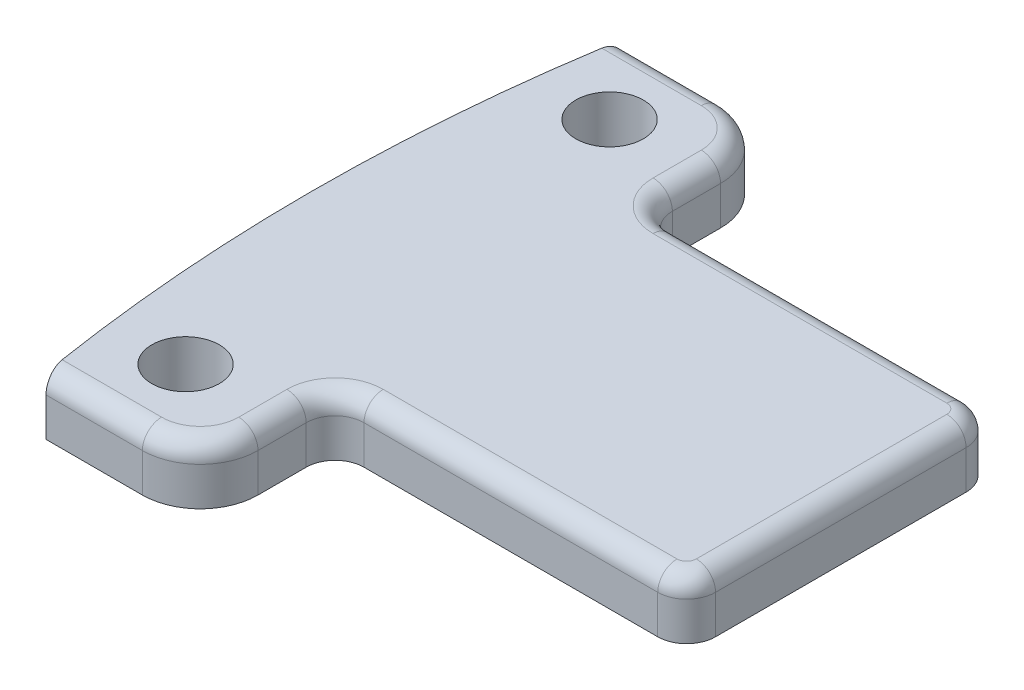
from build123d import *

# Parameters (mm, degrees)
BOSS_EXTRUDE1_DEPTH = 3
SKETCH2_R           = 1.75
CUT_EXTRUDE1_DEPTH  = 4
FILLET1_R           = 1.5
FILLET3_R           = 3
FILLET2_R           = 1


with BuildPart() as part:
    # Sketch1 → Boss-Extrude1 (new body)
    with BuildSketch(Plane(origin=(0, 0, 0), x_dir=(1, 0, 0), z_dir=(0, 1, 0))):
        with BuildLine():
            Line((-12.491196746, 15), (-4.491196746, 15))
            Line((-4.491196746, 15), (-4.491196746, 8))
            Line((-4.491196746, 8), (13.75, 8))
            Line((13.75, 8), (13.75, -8))
            Line((13.75, -8), (-4.491196746, -8))
            Line((-4.491196746, -8), (-4.491196746, -15))
            Line((-4.491196746, -15), (-12.491196746, -15))
            ThreePointArc((-12.491196746, -15), (-13.75, 0), (-12.491196746, 15))
        make_face()
    extrude(amount=BOSS_EXTRUDE1_DEPTH)

    # Sketch2 → Cut-Extrude1 (cut, through all)
    with BuildSketch(Plane(origin=(0, 3, 0), x_dir=(1, 0, 0), z_dir=(0, 1, 0))):
        with Locations((-9.25, 11)):
            Circle(SKETCH2_R)
    cut_extrude1 = extrude(amount=-CUT_EXTRUDE1_DEPTH, mode=Mode.SUBTRACT)

    # Mirror1: Cut-Extrude1 across plane
    add(cut_extrude1.mirror(Plane.XY), mode=Mode.SUBTRACT)

    # Fillet1
    fillet1_edges = [part.edges().sort_by_distance(p)[0] for p in [
        (-4.491196746, 1.5, -8),
        (13.75, 1.5, -8),
        (13.75, 1.5, 8),
        (-4.491196746, 1.5, 8),
    ]]
    fillet(fillet1_edges, radius=FILLET1_R)

    # Fillet3
    fillet3_edges = [part.edges().sort_by_distance(p)[0] for p in [
        (-4.491196746, 1.5, -15),
        (-4.491196746, 1.5, 15),
    ]]
    fillet(fillet3_edges, radius=FILLET3_R)

    # Fillet2
    fillet2_edges = [part.edges().sort_by_distance(p)[0] for p in [
        (-4.491196746, 3, -10.75),
        (4.629401627, 3, -8),
        (4.629401627, 3, 8),
        (13.75, 3, 0),
        (13.310660172, 3, 7.560660172),
        (13.310660172, 3, -7.560660172),
        (-4.051856918, 3, -8.439339828),
        (-4.051856918, 3, 8.439339828),
        (-9.991196746, 3, -15),
        (-4.491196746, 3, 10.75),
        (-5.369876403, 3, 14.121320344),
        (-5.369876403, 3, -14.121320344),
        (-9.991196746, 3, 15),
    ]]
    fillet(fillet2_edges, radius=FILLET2_R)


solid = part.part
